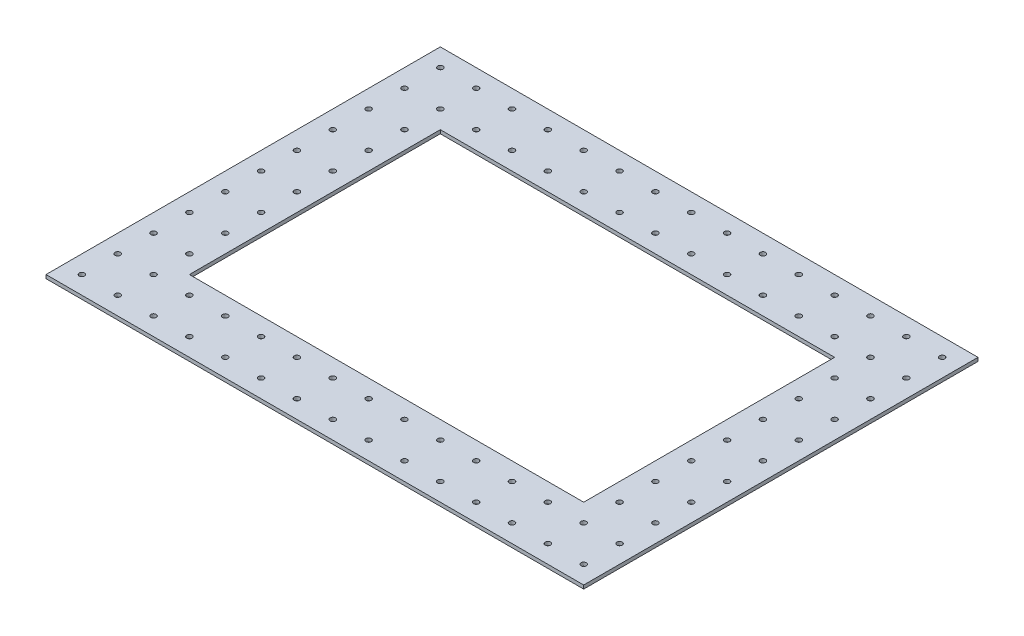
from build123d import *

# Parameters (mm, degrees)
SKETCH1_W           = 220
SKETCH1_H           = 2
BOSS_EXTRUDE1_DEPTH = 300
SKETCH2_R           = 1.5
SKETCH2_W           = 220
SKETCH2_H           = 140
CUT_EXTRUDE1_DEPTH  = 10


with BuildPart() as part:
    # Sketch1 → Boss-Extrude1 (new body)
    with BuildSketch(Plane(origin=(0, 0, 0), x_dir=(0, 0, -1), z_dir=(1, 0, 0))):
        with Locations((83.3216851, 1)):
            Rectangle(SKETCH1_W, SKETCH1_H)
    extrude(amount=BOSS_EXTRUDE1_DEPTH)

    # Sketch2 → Cut-Extrude1 (cut)
    with BuildSketch(Plane(origin=(0, 2, 0), x_dir=(1, 0, 0), z_dir=(0, 1, 0))):
        with Locations((10, -16.6783149)):
            Circle(SKETCH2_R)
        with Locations((30, -16.6783149)):
            Circle(SKETCH2_R)
        with Locations((50, -16.6783149)):
            Circle(SKETCH2_R)
        with Locations((70, -16.6783149)):
            Circle(SKETCH2_R)
        with Locations((90, -16.6783149)):
            Circle(SKETCH2_R)
        with Locations((110, -16.6783149)):
            Circle(SKETCH2_R)
        with Locations((130, -16.6783149)):
            Circle(SKETCH2_R)
        with Locations((150, -16.6783149)):
            Circle(SKETCH2_R)
        with Locations((170, -16.6783149)):
            Circle(SKETCH2_R)
        with Locations((190, -16.6783149)):
            Circle(SKETCH2_R)
        with Locations((210, -16.6783149)):
            Circle(SKETCH2_R)
        with Locations((230, -16.6783149)):
            Circle(SKETCH2_R)
        with Locations((250, -16.6783149)):
            Circle(SKETCH2_R)
        with Locations((270, -16.6783149)):
            Circle(SKETCH2_R)
        with Locations((290, -16.6783149)):
            Circle(SKETCH2_R)
        with Locations((10, 3.3216851)):
            Circle(SKETCH2_R)
        with Locations((270, 3.3216851)):
            Circle(SKETCH2_R)
        with Locations((290, 3.3216851)):
            Circle(SKETCH2_R)
        with Locations((10, 23.3216851)):
            Circle(SKETCH2_R)
        with Locations((30, 23.3216851)):
            Circle(SKETCH2_R)
        with Locations((270, 23.3216851)):
            Circle(SKETCH2_R)
        with Locations((290, 23.3216851)):
            Circle(SKETCH2_R)
        with Locations((10, 43.3216851)):
            Circle(SKETCH2_R)
        with Locations((30, 43.3216851)):
            Circle(SKETCH2_R)
        with Locations((270, 43.3216851)):
            Circle(SKETCH2_R)
        with Locations((290, 43.3216851)):
            Circle(SKETCH2_R)
        with Locations((10, 63.3216851)):
            Circle(SKETCH2_R)
        with Locations((30, 63.3216851)):
            Circle(SKETCH2_R)
        with Locations((270, 63.3216851)):
            Circle(SKETCH2_R)
        with Locations((290, 63.3216851)):
            Circle(SKETCH2_R)
        with Locations((10, 83.3216851)):
            Circle(SKETCH2_R)
        with Locations((30, 83.3216851)):
            Circle(SKETCH2_R)
        with Locations((270, 83.3216851)):
            Circle(SKETCH2_R)
        with Locations((290, 83.3216851)):
            Circle(SKETCH2_R)
        with Locations((10, 103.3216851)):
            Circle(SKETCH2_R)
        with Locations((30, 103.3216851)):
            Circle(SKETCH2_R)
        with Locations((270, 103.3216851)):
            Circle(SKETCH2_R)
        with Locations((290, 103.3216851)):
            Circle(SKETCH2_R)
        with Locations((10, 123.3216851)):
            Circle(SKETCH2_R)
        with Locations((30, 123.3216851)):
            Circle(SKETCH2_R)
        with Locations((270, 123.3216851)):
            Circle(SKETCH2_R)
        with Locations((290, 123.3216851)):
            Circle(SKETCH2_R)
        with Locations((10, 143.3216851)):
            Circle(SKETCH2_R)
        with Locations((30, 143.3216851)):
            Circle(SKETCH2_R)
        with Locations((270, 143.3216851)):
            Circle(SKETCH2_R)
        with Locations((290, 143.3216851)):
            Circle(SKETCH2_R)
        with Locations((10, 163.3216851)):
            Circle(SKETCH2_R)
        with Locations((30, 163.3216851)):
            Circle(SKETCH2_R)
        with Locations((290, 163.3216851)):
            Circle(SKETCH2_R)
        with Locations((10, 183.3216851)):
            Circle(SKETCH2_R)
        with Locations((30, 183.3216851)):
            Circle(SKETCH2_R)
        with Locations((50, 183.3216851)):
            Circle(SKETCH2_R)
        with Locations((70, 183.3216851)):
            Circle(SKETCH2_R)
        with Locations((90, 183.3216851)):
            Circle(SKETCH2_R)
        with Locations((110, 183.3216851)):
            Circle(SKETCH2_R)
        with Locations((130, 183.3216851)):
            Circle(SKETCH2_R)
        with Locations((150, 183.3216851)):
            Circle(SKETCH2_R)
        with Locations((170, 183.3216851)):
            Circle(SKETCH2_R)
        with Locations((190, 183.3216851)):
            Circle(SKETCH2_R)
        with Locations((210, 183.3216851)):
            Circle(SKETCH2_R)
        with Locations((230, 183.3216851)):
            Circle(SKETCH2_R)
        with Locations((250, 183.3216851)):
            Circle(SKETCH2_R)
        with Locations((270, 183.3216851)):
            Circle(SKETCH2_R)
        with Locations((290, 183.3216851)):
            Circle(SKETCH2_R)
        with Locations((50, 163.3216851)):
            Circle(SKETCH2_R)
        with Locations((70, 163.3216851)):
            Circle(SKETCH2_R)
        with Locations((90, 163.3216851)):
            Circle(SKETCH2_R)
        with Locations((110, 163.3216851)):
            Circle(SKETCH2_R)
        with Locations((130, 163.3216851)):
            Circle(SKETCH2_R)
        with Locations((150, 163.3216851)):
            Circle(SKETCH2_R)
        with Locations((170, 163.3216851)):
            Circle(SKETCH2_R)
        with Locations((190, 163.3216851)):
            Circle(SKETCH2_R)
        with Locations((210, 163.3216851)):
            Circle(SKETCH2_R)
        with Locations((230, 163.3216851)):
            Circle(SKETCH2_R)
        with Locations((250, 163.3216851)):
            Circle(SKETCH2_R)
        with Locations((30, 3.3216851)):
            Circle(SKETCH2_R)
        with Locations((50, 3.3216851)):
            Circle(SKETCH2_R)
        with Locations((70, 3.3216851)):
            Circle(SKETCH2_R)
        with Locations((90, 3.3216851)):
            Circle(SKETCH2_R)
        with Locations((110, 3.3216851)):
            Circle(SKETCH2_R)
        with Locations((130, 3.3216851)):
            Circle(SKETCH2_R)
        with Locations((150, 3.3216851)):
            Circle(SKETCH2_R)
        with Locations((170, 3.3216851)):
            Circle(SKETCH2_R)
        with Locations((190, 3.3216851)):
            Circle(SKETCH2_R)
        with Locations((210, 3.3216851)):
            Circle(SKETCH2_R)
        with Locations((230, 3.3216851)):
            Circle(SKETCH2_R)
        with Locations((250, 3.3216851)):
            Circle(SKETCH2_R)
        with Locations((270, 163.3216851)):
            Circle(SKETCH2_R)
        with Locations((150, 83.3216851)):
            Rectangle(SKETCH2_W, SKETCH2_H)
    extrude(amount=-CUT_EXTRUDE1_DEPTH, mode=Mode.SUBTRACT)


solid = part.part
